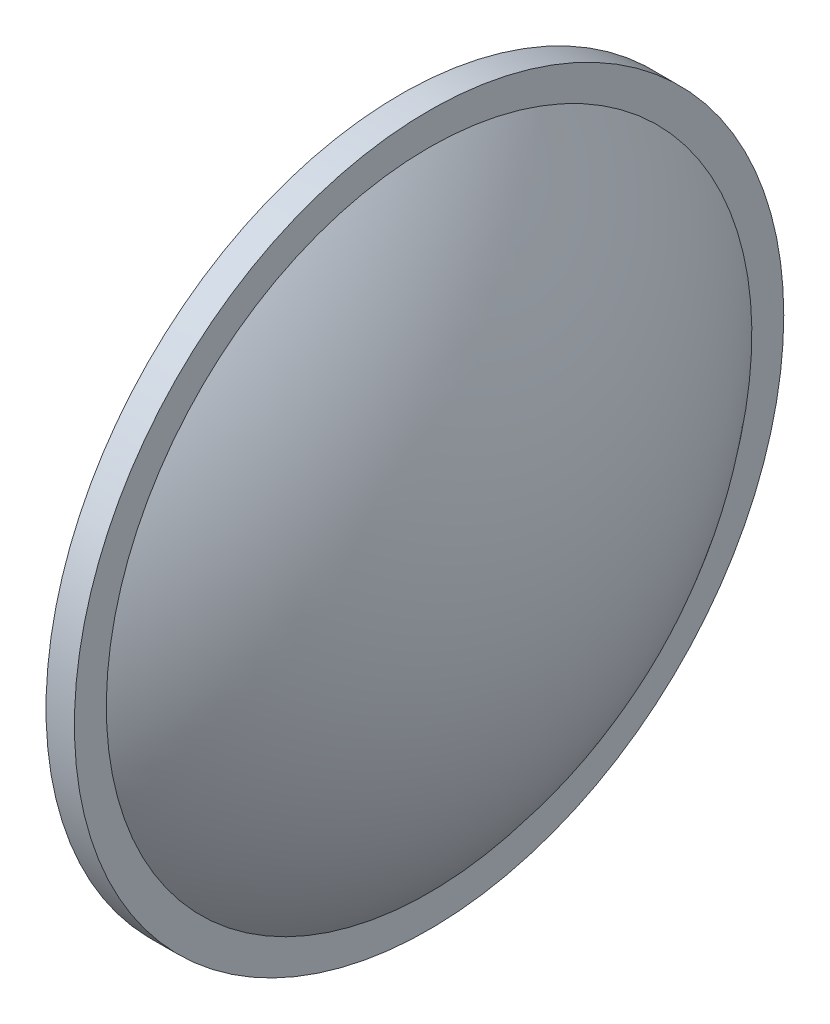
from build123d import *

# Parameters (mm, degrees)
SKETCH_1_R      = 50
EXTRUDE_1_DEPTH = 4


with BuildPart() as part:
    # 草图1 → 凸台-拉伸1 (new body)
    with BuildSketch(Plane(origin=(0, 0, 0), x_dir=(0, 0, -1), z_dir=(1, 0, 0))):
        Circle(SKETCH_1_R)
    extrude(amount=EXTRUDE_1_DEPTH)

    # 草图2 → 旋转2 (revolve)
    with BuildSketch(Plane.XY):
        with BuildLine():
            ThreePointArc((4, 45.5), (16.393134822, 24.23396377), (20.7, 0))
            Line((20.7, 0), (4, 0))
            Line((4, 0), (4, 45.5))
        make_face()
    revolve(axis=Axis((20.7, 0, 0), (-1, 0, 0)))


solid = part.part
